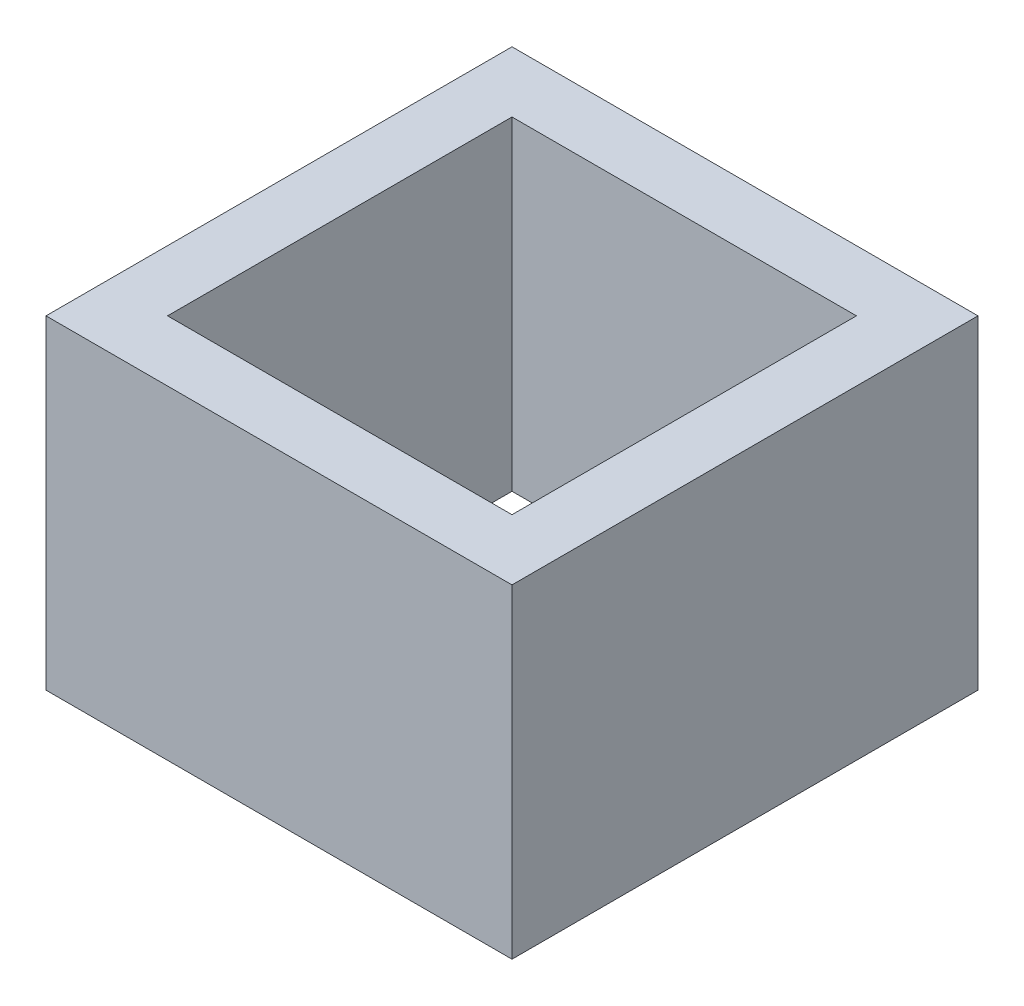
from build123d import *

# Parameters (mm, degrees)
SKETCH1_W           = 11.5
SKETCH1_H           = 11.5
SKETCH1_W_2         = 8.5
SKETCH1_H_2         = 8.5
BOSS_EXTRUDE1_DEPTH = 8


with BuildPart() as part:
    # Sketch1 → Boss-Extrude1 (new body)
    with BuildSketch(Plane(origin=(0, 0, 0), x_dir=(1, 0, 0), z_dir=(0, 1, 0))):
        Rectangle(SKETCH1_W, SKETCH1_H)
        Rectangle(SKETCH1_W_2, SKETCH1_H_2, mode=Mode.SUBTRACT)
    extrude(amount=BOSS_EXTRUDE1_DEPTH)


solid = part.part
